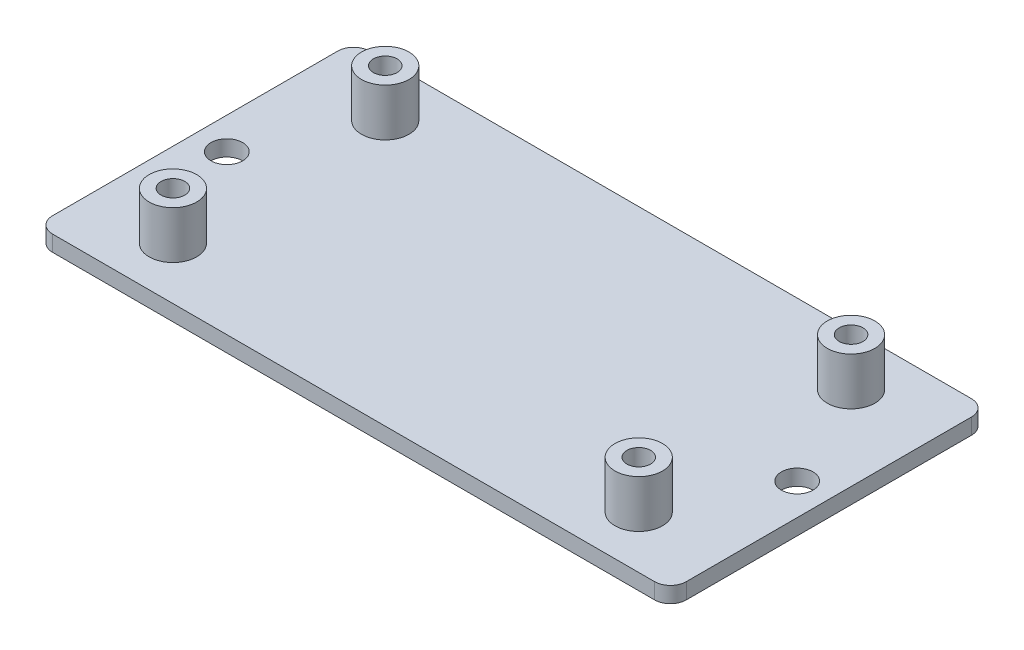
from build123d import *

# Parameters (mm, degrees)
SKETCH_1_W               = 80
SKETCH_1_H               = 40
EXTRUDE_1_DEPTH          = 2
SKETCH_2_R               = 3
EXTRUDE_2_DEPTH          = 6
SKETCH_3_R               = 1.5
CUT_EXTRUDE_1_DEPTH      = 1
CUT_EXTRUDE_1_DEPTH_BACK = 9
SKETCH_4_R               = 2
CUT_EXTRUDE_2_DEPTH      = 7
CUT_EXTRUDE_2_DEPTH_BACK = 3
FILLET_1_R               = 2
FILLET_2_R               = 2
FILLET_3_R               = 2
FILLET_4_R               = 2


with BuildPart() as part:
    # Эскиз1 → Бобышка-Вытянуть1 (new body)
    with BuildSketch(Plane(origin=(0, 0, 0), x_dir=(1, 0, 0), z_dir=(0, 1, 0))):
        with Locations((40, -20)):
            Rectangle(SKETCH_1_W, SKETCH_1_H)
    extrude(amount=EXTRUDE_1_DEPTH)

    # Эскиз2 → Бобышка-Вытянуть2 (add)
    with BuildSketch(Plane(origin=(0, 2, 0), x_dir=(1, 0, 0), z_dir=(0, 1, 0))):
        with Locations((10.6, -6.6)):
            Circle(SKETCH_2_R)
        with Locations((10.6, -33.4)):
            Circle(SKETCH_2_R)
        with Locations((69.4, -6.6)):
            Circle(SKETCH_2_R)
        with Locations((69.4, -33.4)):
            Circle(SKETCH_2_R)
    extrude(amount=EXTRUDE_2_DEPTH)

    # Эскиз3 → Вырез-Вытянуть1 (cut, two sides)
    with BuildSketch(Plane(origin=(0, 8, 0), x_dir=(1, 0, 0), z_dir=(0, 1, 0))) as cut_extrude_1_sk:
        with Locations((10.6, -6.6)):
            Circle(SKETCH_3_R)
        with Locations((10.6, -33.4)):
            Circle(SKETCH_3_R)
        with Locations((69.4, -6.6)):
            Circle(SKETCH_3_R)
        with Locations((69.4, -33.4)):
            Circle(SKETCH_3_R)
    extrude(amount=CUT_EXTRUDE_1_DEPTH, mode=Mode.SUBTRACT)
    extrude(cut_extrude_1_sk.sketch, amount=-CUT_EXTRUDE_1_DEPTH_BACK, mode=Mode.SUBTRACT)

    # Эскиз4 → Вырез-Вытянуть2 (cut, two sides)
    with BuildSketch(Plane(origin=(0, 2, 0), x_dir=(1, 0, 0), z_dir=(0, 1, 0))) as cut_extrude_2_sk:
        with Locations((4, -20)):
            Circle(SKETCH_4_R)
        with Locations((76, -20)):
            Circle(SKETCH_4_R)
    extrude(amount=CUT_EXTRUDE_2_DEPTH, mode=Mode.SUBTRACT)
    extrude(cut_extrude_2_sk.sketch, amount=-CUT_EXTRUDE_2_DEPTH_BACK, mode=Mode.SUBTRACT)

    # Скругление1
    fillet_1_edges = [part.edges().sort_by_distance(p)[0] for p in [
        (0, 1, 0),
    ]]
    fillet(fillet_1_edges, radius=FILLET_1_R)

    # Скругление2
    fillet_2_edges = [part.edges().sort_by_distance(p)[0] for p in [
        (0, 1, 40),
    ]]
    fillet(fillet_2_edges, radius=FILLET_2_R)

    # Скругление3
    fillet_3_edges = [part.edges().sort_by_distance(p)[0] for p in [
        (80, 1, 40),
    ]]
    fillet(fillet_3_edges, radius=FILLET_3_R)

    # Скругление4
    fillet_4_edges = [part.edges().sort_by_distance(p)[0] for p in [
        (80, 1, 0),
    ]]
    fillet(fillet_4_edges, radius=FILLET_4_R)


solid = part.part
